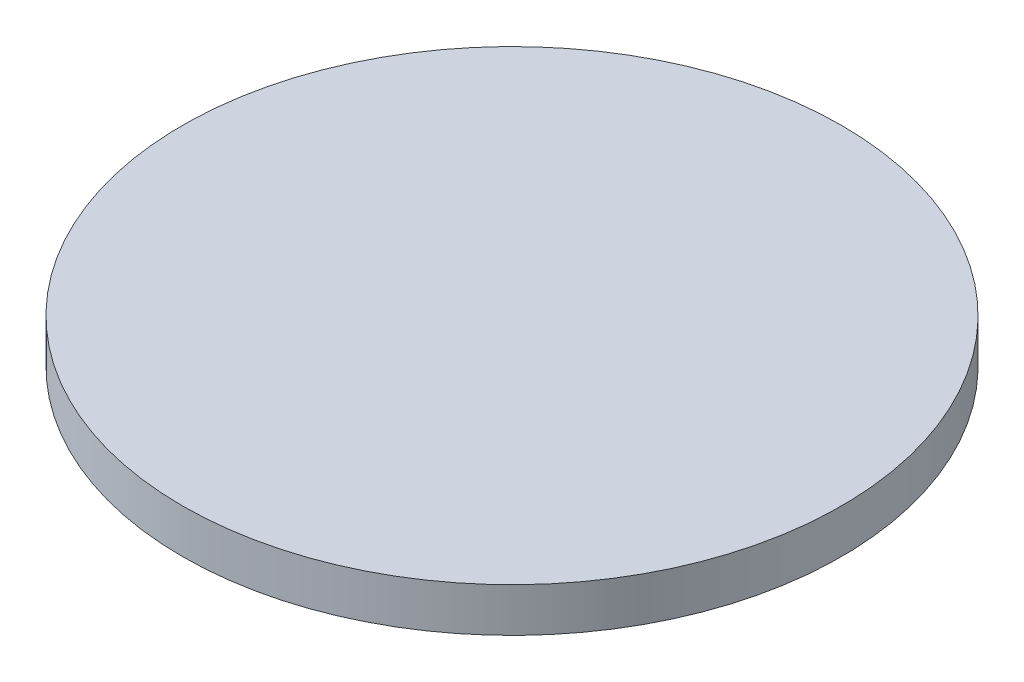
from build123d import *

# Parameters (mm, degrees)
ESQUISSE1_R        = 75
BOSS_EXTRU_1_DEPTH = 10


with BuildPart() as part:
    # Esquisse1 → Boss.-Extru.1 (new body)
    with BuildSketch(Plane(origin=(0, 0, 0), x_dir=(1, 0, 0), z_dir=(0, 1, 0))):
        Circle(ESQUISSE1_R)
    extrude(amount=BOSS_EXTRU_1_DEPTH)


solid = part.part
